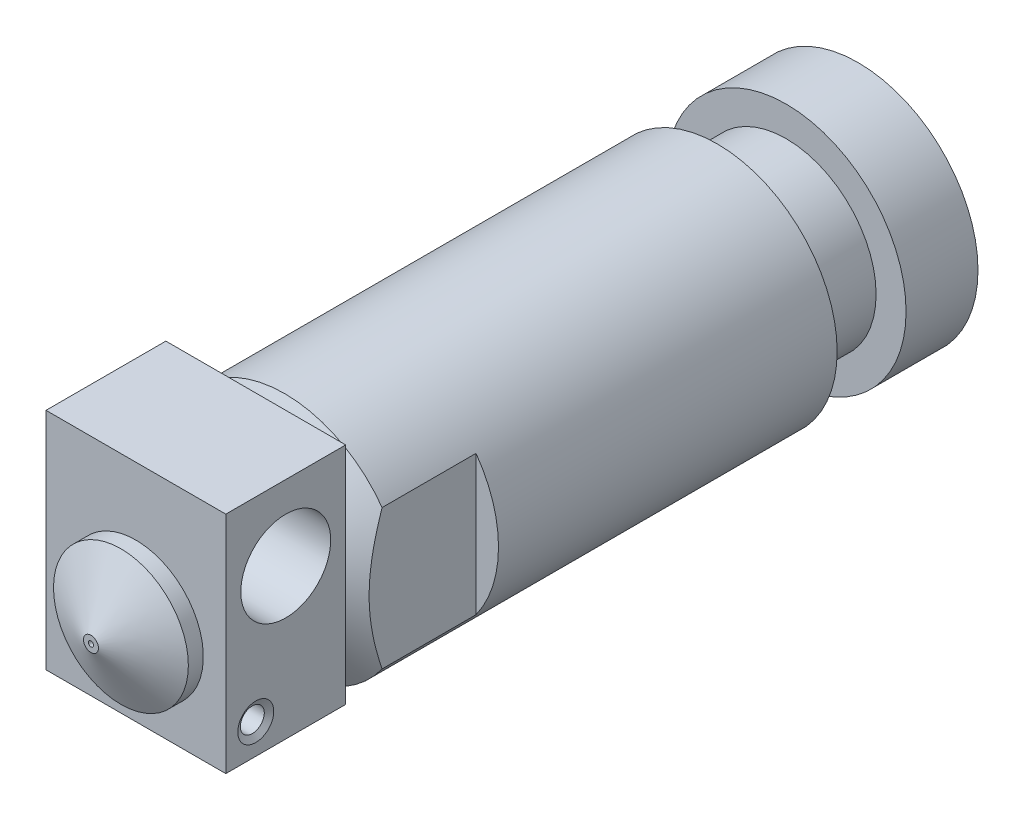
from build123d import *

# Parameters (mm, degrees)
ESQUISSE1_R             = 8
BOSS_EXTRU_1_DEPTH      = 40
ENL_V_START             = -4.8
ESQUISSE2_R             = 8
ESQUISSE2_R_2           = 6
ENL_V_MAT_EXTRU_1_DEPTH = 4.6
CHANFREIN1_SIZE         = 3
CHANFREIN1_SIZE2        = 1.732050808
ESQUISSE3_W             = 2
ESQUISSE3_H             = 12
ENL_V_MAT_EXTRU_2_DEPTH = 8
ESQUISSE4_R             = 1
ESQUISSE8_R             = 1
ENL_V_MAT_EXTRU_4_DEPTH = 41
ESQUISSE9_R             = 4
BOSS_EXTRU_2_DEPTH      = 0.2
ESQUISSE10_W            = 12
ESQUISSE10_H            = 15
BOSS_EXTRU_3_DEPTH      = 8
ESQUISSE11_R            = 3
ENL_V_MAT_EXTRU_5_DEPTH = 15
ESQUISSE13_R            = 0.8
ENL_V_MAT_EXTRU_6_DEPTH = 3
CHANFREIN2_SIZE         = 0.4
CHANFREIN2_SIZE2        = 0.230940108
ESQUISSE14_R            = 4.5
BOSS_EXTRU_4_DEPTH      = 1
ESQUISSE15_R            = 4.5
BOSS_EXTRU_5_DEPTH      = 2
CHANFREIN3_SIZE         = 2
CHANFREIN3_SIZE2        = 4
ESQUISSE16_R            = 0.175
ENL_V_MAT_EXTRU_7_DEPTH = 52.2


with BuildPart() as part:
    # Esquisse1 → Boss.-Extru.1 (new body)
    with BuildSketch(Plane.XY):
        Circle(ESQUISSE1_R)
    extrude(amount=BOSS_EXTRU_1_DEPTH)

    # Esquisse2 → Enlèv. mat.-Extru.1 (cut)
    with BuildSketch(Plane(origin=(0, 0, 0), x_dir=(-1, 0, 0), z_dir=(0, 0, -1)).offset(ENL_V_START)):
        Circle(ESQUISSE2_R)
        Circle(ESQUISSE2_R_2, mode=Mode.SUBTRACT)
    extrude(amount=-ENL_V_MAT_EXTRU_1_DEPTH, mode=Mode.SUBTRACT)

    # Chanfrein1
    chanfrein1_edges = [part.edges().sort_by_distance(p)[0] for p in [
        (-8, 0, 40),
    ]]
    chanfrein1_side = [part.faces().sort_by_distance(p)[0] for p in [
        (0, 0, 40),
    ]]
    chamfer(chanfrein1_edges, length=CHANFREIN1_SIZE, length2=CHANFREIN1_SIZE2, reference=chanfrein1_side[0])

    # Esquisse3 → Enlèv. mat.-Extru.2 (cut)
    with BuildSketch(Plane.XY.offset(40)):
        with Locations((-7.5, 0)):
            Rectangle(ESQUISSE3_W, ESQUISSE3_H)
        with Locations((7.5, 0)):
            Rectangle(ESQUISSE3_W, ESQUISSE3_H)
    extrude(amount=-ENL_V_MAT_EXTRU_2_DEPTH, mode=Mode.SUBTRACT)

    # Esquisse4 → Enlèvement de matière-Révolution1 (revolve, cut)
    with BuildSketch(Plane(origin=(0, 0, 0), x_dir=(1, 0, 0), z_dir=(0, 1, 0))):
        with Locations((-5, -26.5)):
            Circle(ESQUISSE4_R)
        with Locations((-5, -23.5)):
            Circle(ESQUISSE4_R)
        with Locations((-5, -20.5)):
            Circle(ESQUISSE4_R)
        with Locations((-5, -17.5)):
            Circle(ESQUISSE4_R)
        with Locations((-5, -14.5)):
            Circle(ESQUISSE4_R)
    revolve(axis=Axis((0, 0, -7.180896648), (0, 0, 1)), mode=Mode.SUBTRACT)

    # Esquisse8 → Enlèv. mat.-Extru.4 (cut, through all)
    with BuildSketch(Plane(origin=(0, 0, 0), x_dir=(-1, 0, 0), z_dir=(0, 0, -1))):
        Circle(ESQUISSE8_R)
    extrude(amount=-ENL_V_MAT_EXTRU_4_DEPTH, mode=Mode.SUBTRACT)

    # Esquisse9 → Boss.-Extru.2 (add)
    with BuildSketch(Plane.XY.offset(40)):
        Circle(ESQUISSE9_R)
    extrude(amount=BOSS_EXTRU_2_DEPTH)

    # Esquisse10 → Boss.-Extru.3 (add)
    with BuildSketch(Plane.XY.offset(40.2)):
        with Locations((0, 1.5)):
            Rectangle(ESQUISSE10_W, ESQUISSE10_H)
    extrude(amount=BOSS_EXTRU_3_DEPTH)

    # Esquisse11 → Enlèv. mat.-Extru.5 (cut, through all)
    with BuildSketch(Plane(origin=(6, 0, 0), x_dir=(0, 0, -1), z_dir=(1, 0, 0))):
        with Locations((-44.2, 4)):
            Circle(ESQUISSE11_R)
    extrude(amount=-ENL_V_MAT_EXTRU_5_DEPTH, mode=Mode.SUBTRACT)

    # Esquisse13 → Enlèv. mat.-Extru.6 (cut)
    with BuildSketch(Plane(origin=(6, 0, 0), x_dir=(0, 0, -1), z_dir=(1, 0, 0))):
        with Locations((-46.2, -4)):
            Circle(ESQUISSE13_R)
    extrude(amount=-ENL_V_MAT_EXTRU_6_DEPTH, mode=Mode.SUBTRACT)

    # Chanfrein2
    chanfrein2_edges = [part.edges().sort_by_distance(p)[0] for p in [
        (6, -4, 47),
    ]]
    chanfrein2_side = [part.faces().sort_by_distance(p)[0] for p in [
        (6, 0.835368696, 44.155177657),
    ]]
    chamfer(chanfrein2_edges, length=CHANFREIN2_SIZE, length2=CHANFREIN2_SIZE2, reference=chanfrein2_side[0])

    # Esquisse14 → Boss.-Extru.4 (add)
    with BuildSketch(Plane.XY.offset(48.2)):
        Circle(ESQUISSE14_R)
    extrude(amount=BOSS_EXTRU_4_DEPTH)

    # Esquisse15 → Boss.-Extru.5 (add)
    with BuildSketch(Plane.XY.offset(49.2)):
        Circle(ESQUISSE15_R)
    extrude(amount=BOSS_EXTRU_5_DEPTH)

    # Chanfrein3
    chanfrein3_edges = [part.edges().sort_by_distance(p)[0] for p in [
        (-4.5, 0, 51.2),
    ]]
    chanfrein3_side = [part.faces().sort_by_distance(p)[0] for p in [
        (-4.5, 0, 49.7),
    ]]
    chamfer(chanfrein3_edges, length=CHANFREIN3_SIZE, length2=CHANFREIN3_SIZE2, reference=chanfrein3_side[0])

    # Esquisse16 → Enlèv. mat.-Extru.7 (cut, through all)
    with BuildSketch(Plane.XY.offset(51.2)):
        Circle(ESQUISSE16_R)
    extrude(amount=-ENL_V_MAT_EXTRU_7_DEPTH, mode=Mode.SUBTRACT)


solid = part.part
